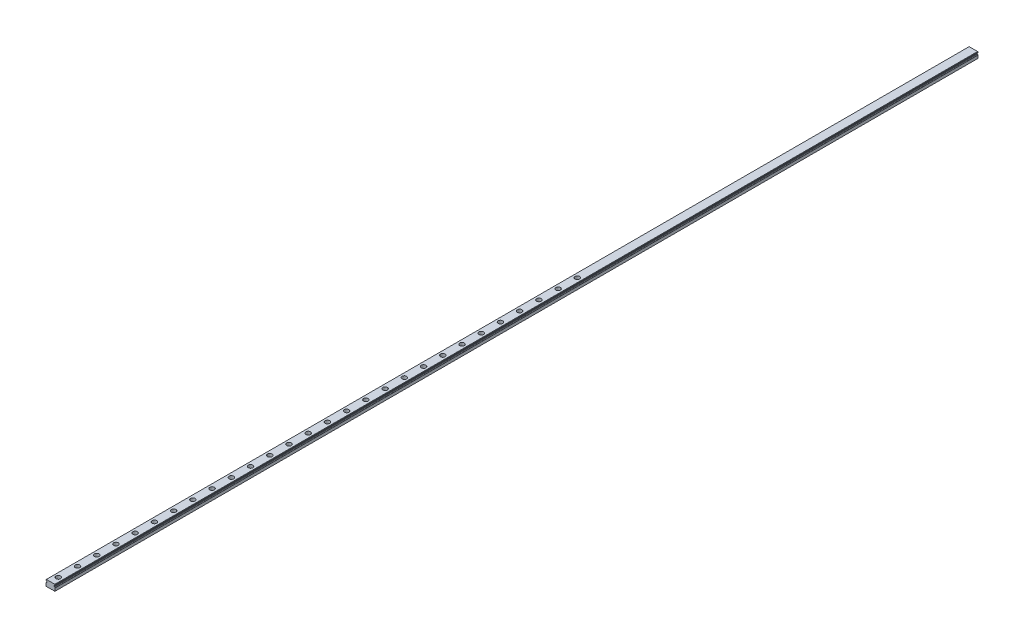
from build123d import *

# Parameters (mm, degrees)
BOSS_EXTRUDE1_START = 600
BOSS_EXTRUDE1_DEPTH = 1200
LPATTERN1_COUNT     = 28
LPATTERN1_PITCH     = 25


with BuildPart() as part:
    # Sketch3 → Boss-Extrude1 (new body)
    with BuildSketch(Plane.XY.offset(BOSS_EXTRUDE1_START)):
        with BuildLine():
            Line((-6, 0.142120421), (-6, -3.5))
            Line((-6, -3.5), (-5.5, -4))
            Line((-5.5, -4), (1.6, -4))
            ThreePointArc((1.6, -4), (2, -3.8), (2.4, -4.000000001))
            Line((2.4, -4.000000001), (5.5, -4.000000001))
            Line((5.5, -4.000000001), (6, -3.500000001))
            Line((6, -3.500000001), (6, 0.14212042))
            ThreePointArc((6, 0.14212042), (5.9576137, 0.281391924), (5.844827586, 0.373437797))
            ThreePointArc((5.844827586, 0.373437797), (5.51524529, 0.575928598), (5.267205011, 0.87275015))
            ThreePointArc((5.267205011, 0.87275015), (5.185241933, 0.957014877), (5.073828324, 0.994504855))
            Line((5.073828324, 0.994504855), (4.728211064, 1.024742447))
            ThreePointArc((4.728211064, 1.024742447), (4.565680666, 1.10489357), (4.5, 1.273791122))
            Line((4.5, 1.273791122), (4.5, 1.726212879))
            ThreePointArc((4.5, 1.726212879), (4.565680666, 1.89511043), (4.728211064, 1.975261553))
            Line((4.728211064, 1.975261553), (5.09477657, 2.007331879))
            ThreePointArc((5.09477657, 2.007331879), (5.203244499, 2.042995575), (5.284541491, 2.123170322))
            ThreePointArc((5.284541491, 2.123170322), (5.527906161, 2.402385779), (5.844827586, 2.594084617))
            ThreePointArc((5.844827586, 2.594084617), (5.9576137, 2.68613049), (6, 2.825401993))
            Line((6, 2.825401993), (6, 3.5))
            Line((6, 3.5), (5.5, 4))
            Line((5.5, 4), (-5.5, 4))
            Line((-5.5, 4), (-6, 3.5))
            Line((-6, 3.5), (-6, 2.825401994))
            ThreePointArc((-6, 2.825401994), (-5.9576137, 2.68613049), (-5.844827586, 2.594084617))
            ThreePointArc((-5.844827586, 2.594084617), (-5.527906161, 2.402385779), (-5.284541491, 2.123170322))
            ThreePointArc((-5.284541491, 2.123170322), (-5.203244499, 2.042995575), (-5.09477657, 2.007331879))
            Line((-5.09477657, 2.007331879), (-4.728211064, 1.975261553))
            ThreePointArc((-4.728211064, 1.975261553), (-4.565680666, 1.89511043), (-4.5, 1.726212879))
            Line((-4.5, 1.726212879), (-4.5, 1.273791122))
            ThreePointArc((-4.5, 1.273791122), (-4.565680666, 1.10489357), (-4.728211064, 1.024742447))
            Line((-4.728211064, 1.024742447), (-5.073828324, 0.994504855))
            ThreePointArc((-5.073828324, 0.994504855), (-5.185241933, 0.957014877), (-5.267205011, 0.87275015))
            ThreePointArc((-5.267205011, 0.87275015), (-5.51524529, 0.575928598), (-5.844827586, 0.373437797))
            ThreePointArc((-5.844827586, 0.373437797), (-5.9576137, 0.281391924), (-6, 0.142120421))
        make_face()
    extrude(amount=-BOSS_EXTRUDE1_DEPTH)

    # Sketch4 → Cut-Revolve1 (revolve, cut)
    with BuildSketch(Plane.XY.offset(590)):
        Polygon((0, 4), (0, -4), (-1.75, -4), (-1.75, -0.5), (-3, -0.5), (-3, 4), align=None)
    cut_revolve1 = revolve(axis=Axis((0, 4, 590), (0, -1, 0)), mode=Mode.SUBTRACT)

    # LPattern1: Cut-Revolve1 ×28
    with Locations(*[(0, 0, -i * LPATTERN1_PITCH) for i in range(1, LPATTERN1_COUNT)]):
        add(cut_revolve1, mode=Mode.SUBTRACT)


solid = part.part
